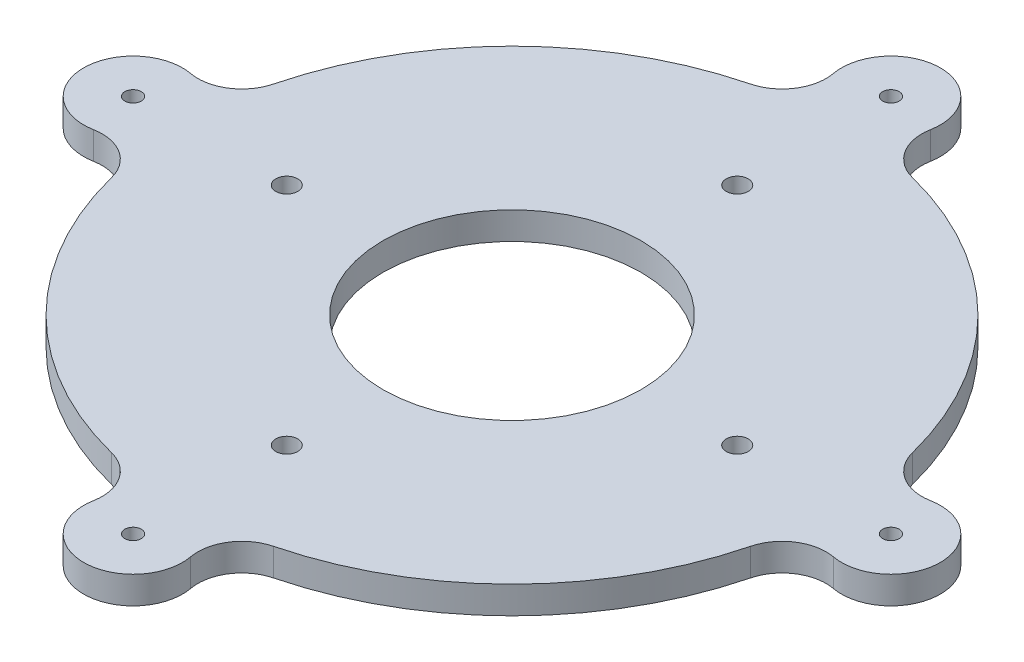
from build123d import *

# Parameters (mm, degrees)
SKETCH1_R           = 23.5
SKETCH1_R_2         = 1.5
SKETCH1_R_3         = 2
BOSS_EXTRUDE1_DEPTH = 5


with BuildPart() as part:
    # Sketch1 → Boss-Extrude1 (new body)
    with BuildSketch(Plane(origin=(0, 0, 0), x_dir=(1, 0, 0), z_dir=(0, 1, 0))):
        with BuildLine():
            ThreePointArc((58.158567775, 14.750626914), (42.426406871, 42.426406871), (14.750626914, 58.158567775))
            ThreePointArc((14.750626914, 58.158567775), (9.981753959, 61.596635254), (8.850376149, 67.3657289))
            ThreePointArc((8.850376149, 67.3657289), (0, 78), (-8.850376149, 67.3657289))
            ThreePointArc((-8.850376149, 67.3657289), (-9.981753959, 61.596635254), (-14.750626914, 58.158567775))
            ThreePointArc((-14.750626914, 58.158567775), (-42.426406871, 42.426406871), (-58.158567775, 14.750626914))
            ThreePointArc((-58.158567775, 14.750626914), (-61.596635254, 9.981753959), (-67.3657289, 8.850376149))
            ThreePointArc((-67.3657289, 8.850376149), (-78, 0), (-67.3657289, -8.850376149))
            ThreePointArc((-67.3657289, -8.850376149), (-61.596635254, -9.981753959), (-58.158567775, -14.750626914))
            ThreePointArc((-58.158567775, -14.750626914), (-42.426406871, -42.426406871), (-14.750626914, -58.158567775))
            ThreePointArc((-14.750626914, -58.158567775), (-9.981753959, -61.596635254), (-8.850376149, -67.3657289))
            ThreePointArc((-8.850376149, -67.3657289), (0, -78), (8.850376149, -67.3657289))
            ThreePointArc((8.850376149, -67.3657289), (9.981753959, -61.596635254), (14.750626914, -58.158567775))
            ThreePointArc((14.750626914, -58.158567775), (42.426406871, -42.426406871), (58.158567775, -14.750626914))
            ThreePointArc((58.158567775, -14.750626914), (61.596635254, -9.981753959), (67.3657289, -8.850376149))
            ThreePointArc((67.3657289, -8.850376149), (78, 0), (67.3657289, 8.850376149))
            ThreePointArc((67.3657289, 8.850376149), (61.596635254, 9.981753959), (58.158567775, 14.750626914))
        make_face()
        Circle(SKETCH1_R, mode=Mode.SUBTRACT)
        with Locations((69, 0)):
            Circle(SKETCH1_R_2, mode=Mode.SUBTRACT)
        with Locations((41.01219331, 0)):
            Circle(SKETCH1_R_3, mode=Mode.SUBTRACT)
        with Locations((0, 41.01219331)):
            Circle(SKETCH1_R_3, mode=Mode.SUBTRACT)
        with Locations((-41.01219331, 0)):
            Circle(SKETCH1_R_3, mode=Mode.SUBTRACT)
        with Locations((0, -41.01219331)):
            Circle(SKETCH1_R_3, mode=Mode.SUBTRACT)
        with Locations((0, 69)):
            Circle(SKETCH1_R_2, mode=Mode.SUBTRACT)
        with Locations((0, -69)):
            Circle(SKETCH1_R_2, mode=Mode.SUBTRACT)
        with Locations((-69, 0)):
            Circle(SKETCH1_R_2, mode=Mode.SUBTRACT)
    extrude(amount=BOSS_EXTRUDE1_DEPTH)


solid = part.part
